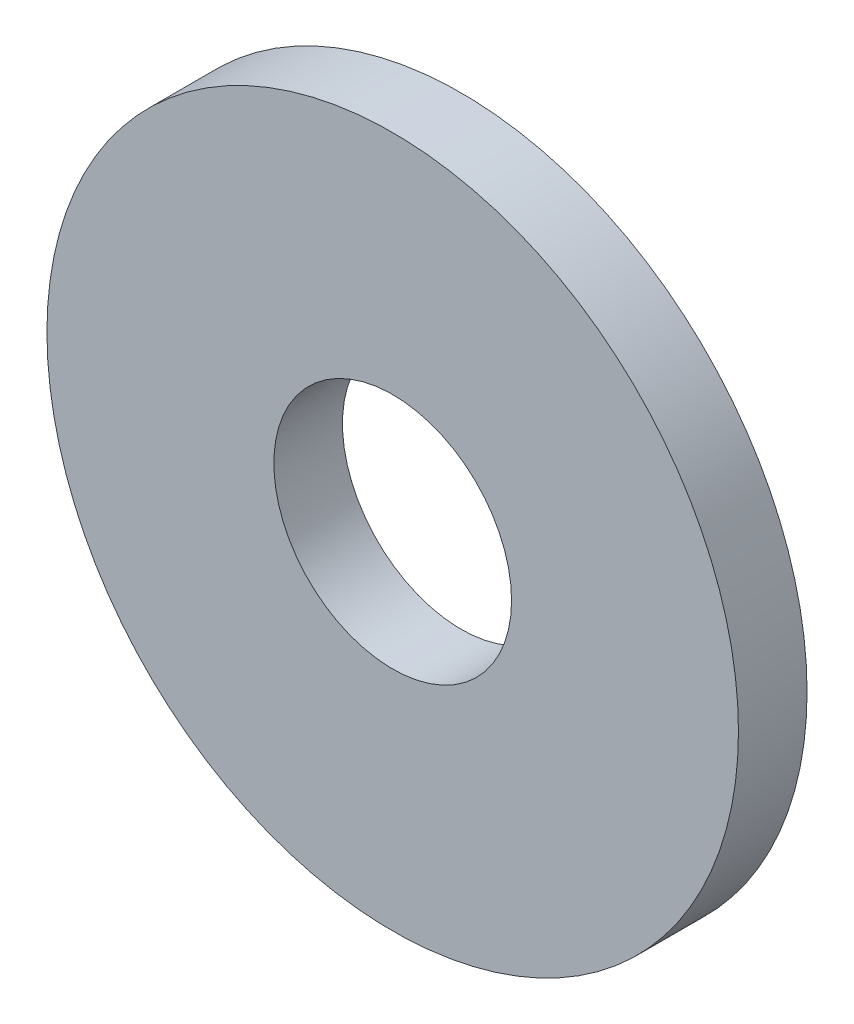
from build123d import *

# Parameters (mm, degrees)
SKETCH1_R           = 32
SKETCH1_R_2         = 11
BOSS_EXTRUDE1_DEPTH = 6.35


with BuildPart() as part:
    # Sketch1 → Boss-Extrude1 (new body)
    with BuildSketch(Plane.XY):
        Circle(SKETCH1_R)
        Circle(SKETCH1_R_2, mode=Mode.SUBTRACT)
    extrude(amount=BOSS_EXTRUDE1_DEPTH)


solid = part.part
